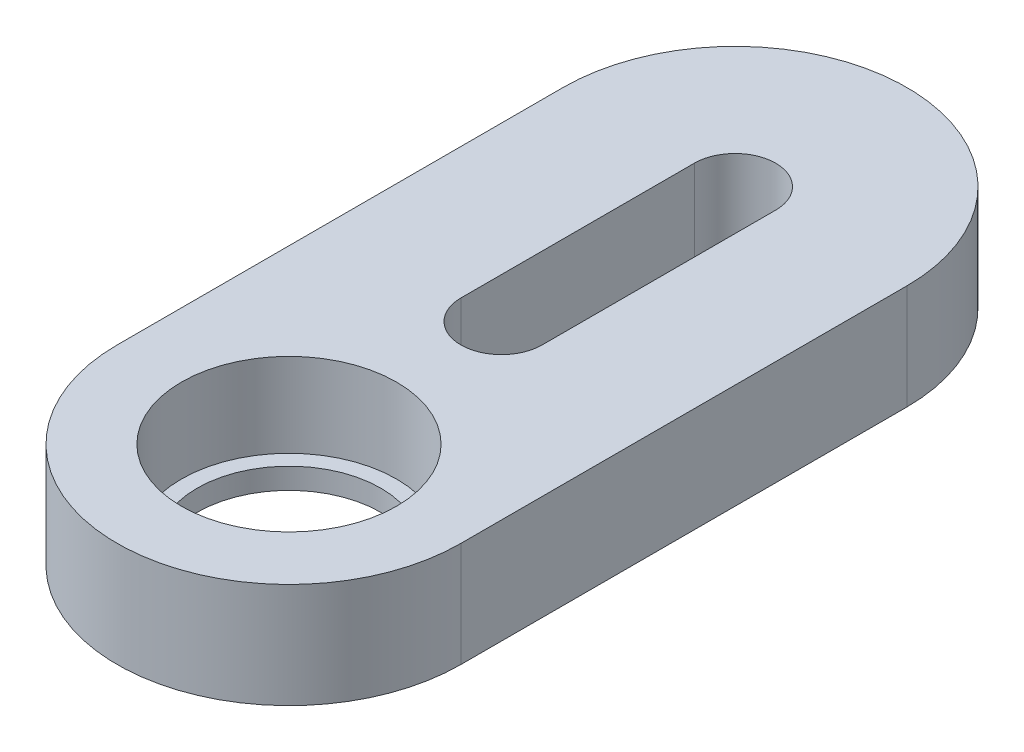
from build123d import *

# Parameters (mm, degrees)
SKETCH1_R           = 4.1
BOSS_EXTRUDE1_DEPTH = 4
SKETCH2_R           = 4.1
BOSS_EXTRUDE2_DEPTH = 0.8
SKETCH3_R           = 3.5
CUT_EXTRUDE1_DEPTH  = 1.8


with BuildPart() as part:
    # Sketch1 → Boss-Extrude1 (new body)
    with BuildSketch(Plane(origin=(0, 0, 0), x_dir=(1, 0, 0), z_dir=(0, 1, 0))):
        with BuildLine():
            ThreePointArc((-6.55, 0), (0, -6.55), (6.55, 0))
            Line((6.55, 0), (6.55, 17))
            ThreePointArc((6.55, 17), (0, 23.55), (-6.55, 17))
            Line((-6.55, 17), (-6.55, 0))
        make_face()
        Circle(SKETCH1_R, mode=Mode.SUBTRACT)
        with BuildLine():
            Line((-1.55, 8.1), (-1.55, 17))
            ThreePointArc((-1.55, 17), (0, 18.55), (1.55, 17))
            Line((1.55, 17), (1.55, 8.1))
            ThreePointArc((1.55, 8.1), (0, 6.55), (-1.55, 8.1))
        make_face(mode=Mode.SUBTRACT)
    extrude(amount=BOSS_EXTRUDE1_DEPTH)

    # Sketch2 → Boss-Extrude2 (add)
    with BuildSketch(Plane(origin=(0, 0, 0), x_dir=(1, 0, 0), z_dir=(0, 1, 0))):
        Circle(SKETCH2_R)
    extrude(amount=BOSS_EXTRUDE2_DEPTH)

    # Sketch3 → Cut-Extrude1 (cut, through all)
    with BuildSketch(Plane(origin=(0, 0.8, 0), x_dir=(1, 0, 0), z_dir=(0, 1, 0))):
        Circle(SKETCH3_R)
    extrude(amount=-CUT_EXTRUDE1_DEPTH, mode=Mode.SUBTRACT)


solid = part.part
